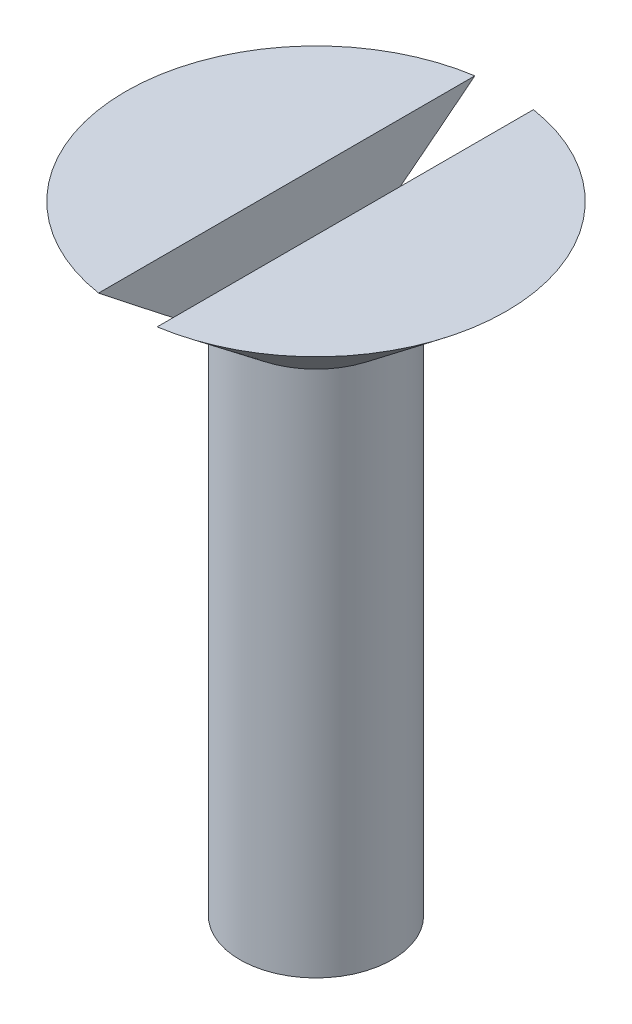
from build123d import *

# Parameters (mm, degrees)
SKETCH3_W          = 2
SKETCH3_H          = 15
CUT_EXTRUDE1_DEPTH = 2


with BuildPart() as part:
    # Sketch1 → Revolve1 (revolve)
    with BuildSketch(Plane.XY):
        Polygon((0, 0), (2.598076211, 1.5), (2.598076211, 19.5), (6.5, 22.62649816), (0, 22.62649816), align=None)
    revolve(axis=Axis((0, 22.62649816, 0), (0, -1, 0)))

    # Sketch3 → Cut-Extrude1 (cut)
    with BuildSketch(Plane(origin=(0, 22.62649816, 0), x_dir=(1, 0, 0), z_dir=(0, 1, 0))):
        Rectangle(SKETCH3_W, SKETCH3_H)
    extrude(amount=-CUT_EXTRUDE1_DEPTH, mode=Mode.SUBTRACT)


solid = part.part
